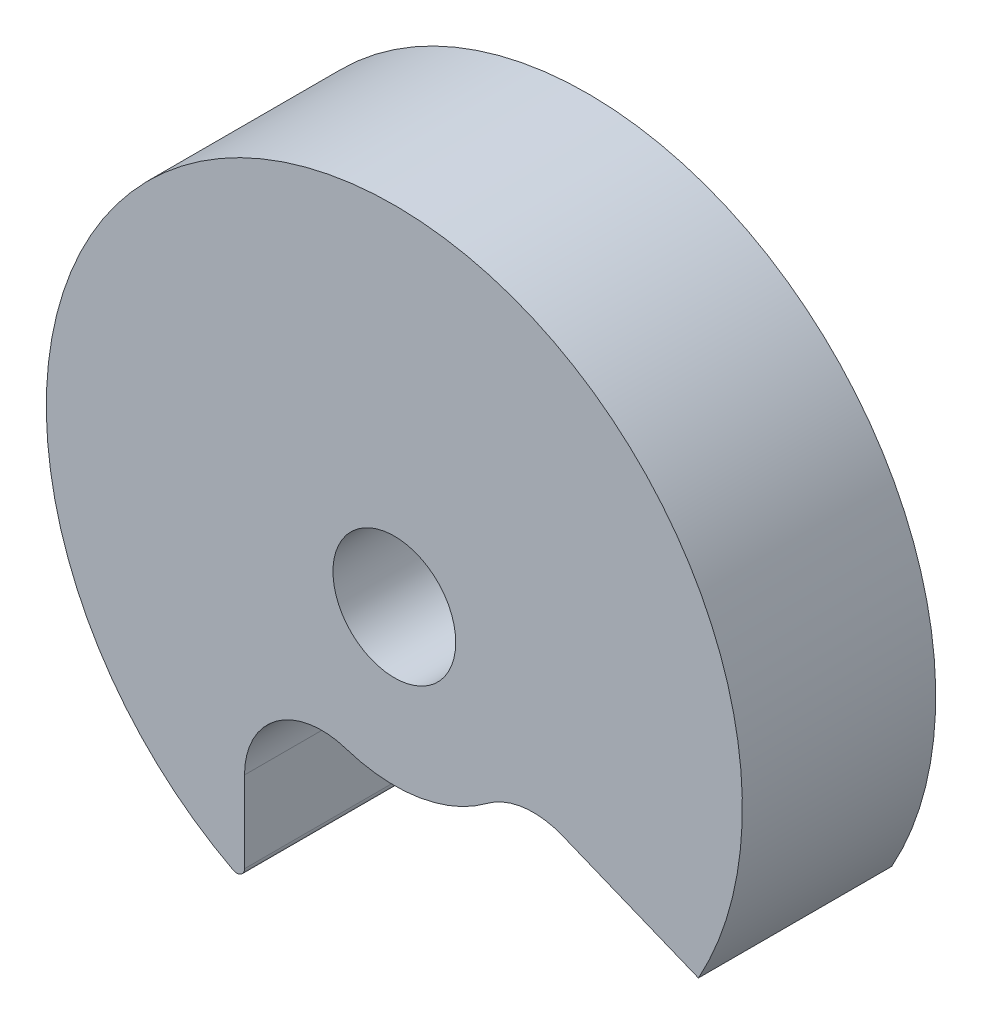
from build123d import *

# Parameters (mm, degrees)
SKETCH2_R           = 9
SKETCH2_R_2         = 1.5875
BOSS_EXTRUDE2_DEPTH = 5
CUT_EXTRUDE1_DEPTH  = 6
FILLET1_R           = 0.2


with BuildPart() as part:
    # Sketch2 → Boss-Extrude2 (new body)
    with BuildSketch(Plane.XY):
        with Locations((-0.284627084, 9.330933041)):
            Circle(SKETCH2_R)
        with Locations((-0.284627084, 9.330933041)):
            Circle(SKETCH2_R_2, mode=Mode.SUBTRACT)
    extrude(amount=BOSS_EXTRUDE2_DEPTH)

    # Sketch3 → Cut-Extrude1 (cut, through all)
    with BuildSketch(Plane.XY.offset(5)):
        with BuildLine():
            Line((-4.158820782, 1.20747176), (-4.158820782, 3.631161293))
            ThreePointArc((-4.158820782, 3.631161293), (-3.331539319, 5.251263522), (-1.534089549, 5.531085209))
            ThreePointArc((-1.534089549, 5.531085209), (0.362418992, 5.383613523), (2.112594321, 6.128850978))
            ThreePointArc((2.112594321, 6.128850978), (3.05528193, 6.511368207), (4.064188319, 6.380649971))
            Line((4.064188319, 6.380649971), (7.578508136, 4.952451053))
            ThreePointArc((7.578508136, 4.952451053), (2.451086916, 0.756793497), (-4.158820782, 1.20747176))
        make_face()
    extrude(amount=-CUT_EXTRUDE1_DEPTH, mode=Mode.SUBTRACT)

    # Fillet1
    fillet1_edges = [part.edges().sort_by_distance(p)[0] for p in [
        (-4.158820782, 1.20747176, 2.5),
    ]]
    fillet(fillet1_edges, radius=FILLET1_R)


solid = part.part
